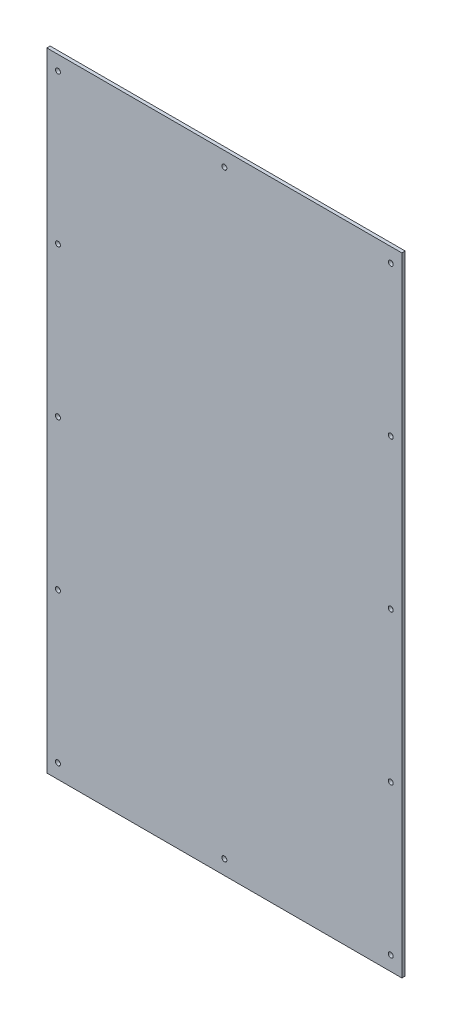
from build123d import *

# Parameters (mm, degrees)
SKETCH_1_W      = 320
SKETCH_1_H      = 566
SKETCH_1_R      = 2.25
EXTRUDE_1_DEPTH = 3


with BuildPart() as part:
    # Эскиз1 → Бобышка-Вытянуть1 (new body)
    with BuildSketch(Plane.XY):
        with Locations((160, 283)):
            Rectangle(SKETCH_1_W, SKETCH_1_H)
        with Locations((10, 553)):
            Circle(SKETCH_1_R, mode=Mode.SUBTRACT)
        with Locations((10, 418)):
            Circle(SKETCH_1_R, mode=Mode.SUBTRACT)
        with Locations((10, 283)):
            Circle(SKETCH_1_R, mode=Mode.SUBTRACT)
        with Locations((10, 148)):
            Circle(SKETCH_1_R, mode=Mode.SUBTRACT)
        with Locations((10, 13)):
            Circle(SKETCH_1_R, mode=Mode.SUBTRACT)
        with Locations((160, 553)):
            Circle(SKETCH_1_R, mode=Mode.SUBTRACT)
        with Locations((160, 13)):
            Circle(SKETCH_1_R, mode=Mode.SUBTRACT)
        with Locations((310, 553)):
            Circle(SKETCH_1_R, mode=Mode.SUBTRACT)
        with Locations((310, 418)):
            Circle(SKETCH_1_R, mode=Mode.SUBTRACT)
        with Locations((310, 283)):
            Circle(SKETCH_1_R, mode=Mode.SUBTRACT)
        with Locations((310, 148)):
            Circle(SKETCH_1_R, mode=Mode.SUBTRACT)
        with Locations((310, 13)):
            Circle(SKETCH_1_R, mode=Mode.SUBTRACT)
    extrude(amount=EXTRUDE_1_DEPTH)


solid = part.part
